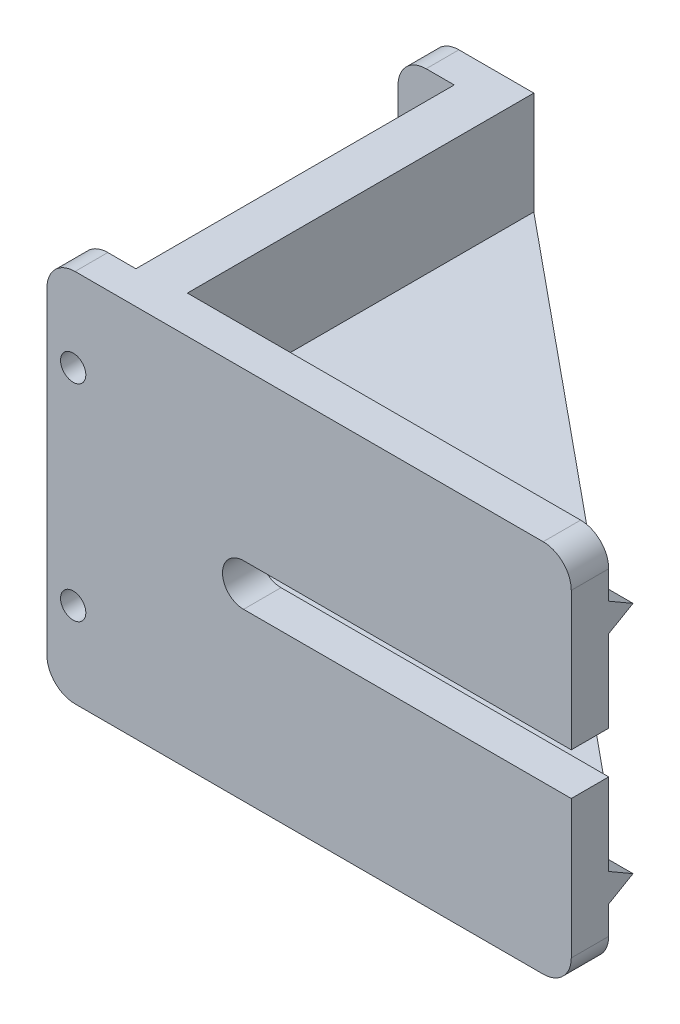
from build123d import *

# Parameters (mm, degrees)
SKETCH_1_W               = 41
SKETCH_1_H               = 40
EXTRUDE_1_DEPTH          = 5
SKETCH_2_W               = 3.5
SKETCH_2_H               = 40
EXTRUDE_2_DEPTH          = 6
EXTRUDE_3_DEPTH          = 45
SKETCH_4_W               = 45
SKETCH_4_H               = 4
EXTRUDE_4_DEPTH          = 37
CUT_EXTRUDE_1_DEPTH      = 19
SKETCH_6_R               = 1.35
CUT_EXTRUDE_2_DEPTH      = 42
FILLET_1_R               = 3
FILLET_2_R               = 3
CUT_EXTRUDE_3_DEPTH      = 38
CUT_EXTRUDE_3_DEPTH_BACK = 5
SKETCH_8_R               = 1.25
CUT_EXTRUDE_4_DEPTH      = 5


with BuildPart() as part:
    # 스케치1 → 보스-돌출1 (new body)
    with BuildSketch(Plane(origin=(0, 0, 0), x_dir=(0, 0, -1), z_dir=(1, 0, 0))):
        with Locations((20.5, 20)):
            Rectangle(SKETCH_1_W, SKETCH_1_H)
    extrude(amount=EXTRUDE_1_DEPTH)

    # 스케치2 → 보스-돌출2 (add)
    with BuildSketch(Plane.ZY):
        with Locations((-1.75, 20)):
            Rectangle(SKETCH_2_W, SKETCH_2_H)
        with Locations((-39.25, 20)):
            Rectangle(SKETCH_2_W, SKETCH_2_H)
    extrude(amount=EXTRUDE_2_DEPTH)

    # 스케치3 → 보스-돌출3 (add)
    with BuildSketch(Plane(origin=(5, 0, 0), x_dir=(0, 0, -1), z_dir=(1, 0, 0))):
        Polygon((0, 40), (4, 40), (4, 34), (6.598076211, 32.5), (4, 31), (4, 14), (4, 12), (4, 9), (6.598076211, 7.5), (4, 6), (4, 0), (0, 0), align=None)
    extrude(amount=EXTRUDE_3_DEPTH)

    # 스케치4 → 보스-돌출4 (add)
    with BuildSketch(Plane(origin=(0, 0, -4), x_dir=(-1, 0, 0), z_dir=(0, 0, -1))):
        with Locations((-27.5, 27)):
            Rectangle(SKETCH_4_W, SKETCH_4_H)
        with Locations((-27.5, 13)):
            Rectangle(SKETCH_4_W, SKETCH_4_H)
    extrude(amount=EXTRUDE_4_DEPTH)

    # 스케치5 → 컷-돌출1 (cut)
    with BuildSketch(Plane(origin=(0, 29, 0), x_dir=(1, 0, 0), z_dir=(0, 1, 0))):
        Polygon((50, 4), (5, 41), (50, 41), align=None)
    extrude(amount=-CUT_EXTRUDE_1_DEPTH, mode=Mode.SUBTRACT)

    # 스케치6 → 컷-돌출2 (cut, through all)
    with BuildSketch(Plane(origin=(0, 0, -41), x_dir=(-1, 0, 0), z_dir=(0, 0, -1))):
        with Locations((3.2, 9)):
            Circle(SKETCH_6_R)
        with Locations((3.2, 31)):
            Circle(SKETCH_6_R)
    extrude(amount=-CUT_EXTRUDE_2_DEPTH, mode=Mode.SUBTRACT)

    # 필렛1
    fillet_1_edges = [part.edges().sort_by_distance(p)[0] for p in [
        (50, 0, -2),
        (50, 40, -2),
    ]]
    fillet(fillet_1_edges, radius=FILLET_1_R)

    # 필렛2
    fillet_2_edges = [part.edges().sort_by_distance(p)[0] for p in [
        (-6, 0, -1.75),
        (-6, 40, -1.75),
        (-6, 40, -39.25),
        (-6, 0, -39.25),
    ]]
    fillet(fillet_2_edges, radius=FILLET_2_R)

    # 스케치7 → 컷-돌출3 (cut, two sides)
    with BuildSketch(Plane(origin=(0, 0, -4), x_dir=(-1, 0, 0), z_dir=(0, 0, -1))) as cut_extrude_3_sk:
        with BuildLine():
            Line((-40, 22.25), (-15, 22.25))
            ThreePointArc((-15, 22.25), (-12.75, 20), (-15, 17.75))
            Line((-15, 17.75), (-40, 17.75))
            Line((-40, 17.75), (-50, 17.75))
            Line((-50, 17.75), (-50, 22.25))
            Line((-50, 22.25), (-40, 22.25))
        make_face()
    extrude(amount=CUT_EXTRUDE_3_DEPTH, mode=Mode.SUBTRACT)
    extrude(cut_extrude_3_sk.sketch, amount=-CUT_EXTRUDE_3_DEPTH_BACK, mode=Mode.SUBTRACT)

    # 스케치8 → 컷-돌출4 (cut)
    with BuildSketch(Plane(origin=(0, 0, -41), x_dir=(-1, 0, 0), z_dir=(0, 0, -1))):
        with Locations((-2.3, 31)):
            Circle(SKETCH_8_R)
        with Locations((-2.3, 9)):
            Circle(SKETCH_8_R)
    extrude(amount=-CUT_EXTRUDE_4_DEPTH, mode=Mode.SUBTRACT)


solid = part.part
